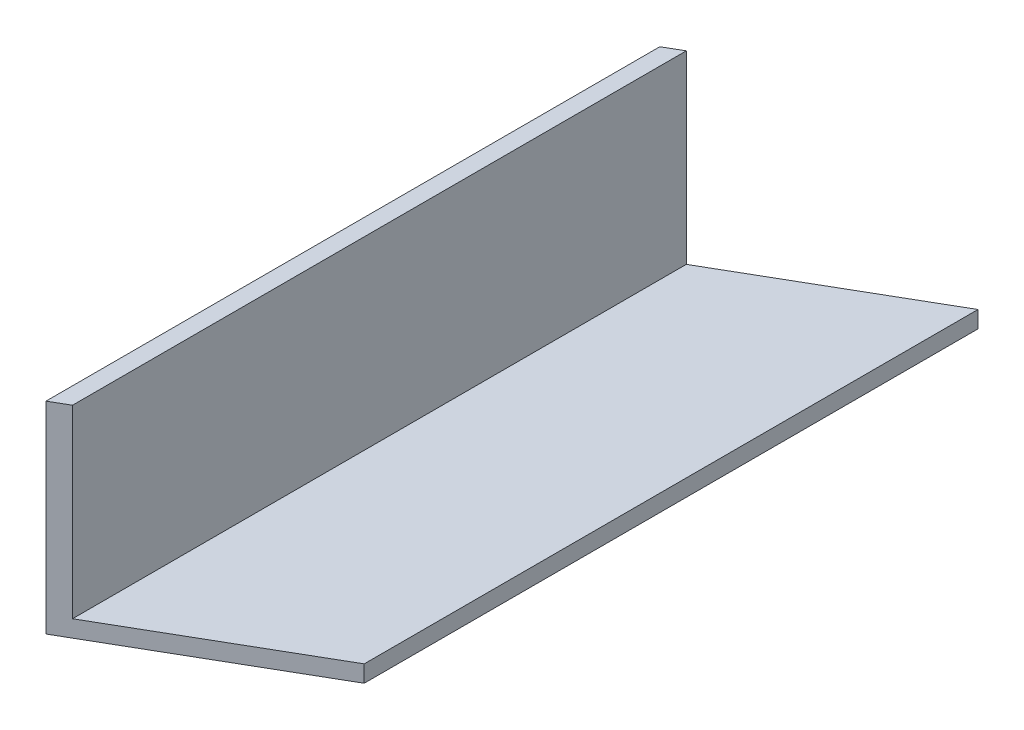
from build123d import *

# Parameters (mm, degrees)
SKETCH1_W           = 38.1
SKETCH1_H           = 38.1
BOSS_EXTRUDE1_DEPTH = 137.922
SKETCH2_W           = 34.925
SKETCH2_H           = 34.925
CUT_EXTRUDE1_DEPTH  = 138.922
CUT_EXTRUDE2_DEPTH  = 39.1


with BuildPart() as part:
    # Sketch1 → Boss-Extrude1 (new body)
    with BuildSketch(Plane.XY):
        with Locations((19.05, 19.05)):
            Rectangle(SKETCH1_W, SKETCH1_H)
    extrude(amount=BOSS_EXTRUDE1_DEPTH)

    # Sketch2 → Cut-Extrude1 (cut, through all)
    with BuildSketch(Plane.XY.offset(137.922)):
        with Locations((20.6375, 20.6375)):
            Rectangle(SKETCH2_W, SKETCH2_H)
    extrude(amount=-CUT_EXTRUDE1_DEPTH, mode=Mode.SUBTRACT)

    # Sketch3 → Cut-Extrude2 (cut, through all)
    with BuildSketch(Plane.XZ):
        Polygon((0, 137.922), (38.1, 137.922), (38.1, 115.924954744), align=None)
        Polygon((38.1, 0), (0, 0), (0, 21.997045256), align=None)
    extrude(amount=-CUT_EXTRUDE2_DEPTH, mode=Mode.SUBTRACT)


solid = part.part
